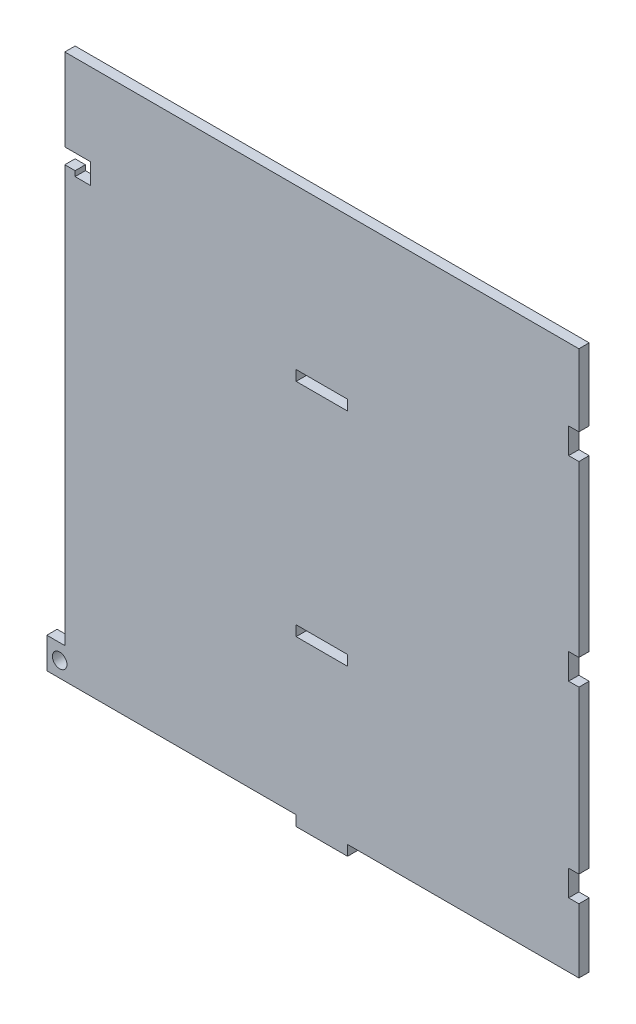
from build123d import *

# Parameters (mm, degrees)
SKETCH1_R           = 1.414213562
SKETCH1_W           = 10
SKETCH1_H           = 2
BOSS_EXTRUDE1_DEPTH = 2


with BuildPart() as part:
    # Sketch1 → Boss-Extrude1 (new body)
    with BuildSketch(Plane.XY):
        Polygon((-53.5, 0), (-50, 0), (-5, 0), (5, 0), (50, 0), (50, 12.5), (48, 12.5), (48, 17.5), (50, 17.5), (50, 30), (50, 49), (48, 49), (48, 54), (50, 54), (50, 73), (50, 87), (48, 87), (48, 92), (50, 92), (50, 106), (-50, 106), (-50, 90), (-45, 90), (-45, 87), (-45, 86), (-48, 86), (-48, 87), (-50, 87), (-50, 6), (-53.5, 6), align=None)
        with Locations((-51, 3)):
            Circle(SKETCH1_R, mode=Mode.SUBTRACT)
        with Locations((0, 31)):
            Rectangle(SKETCH1_W, SKETCH1_H, mode=Mode.SUBTRACT)
        with Locations((0, 74)):
            Rectangle(SKETCH1_W, SKETCH1_H, mode=Mode.SUBTRACT)
        with Locations((0, -1)):
            Rectangle(SKETCH1_W, SKETCH1_H)
    extrude(amount=BOSS_EXTRUDE1_DEPTH)


solid = part.part
